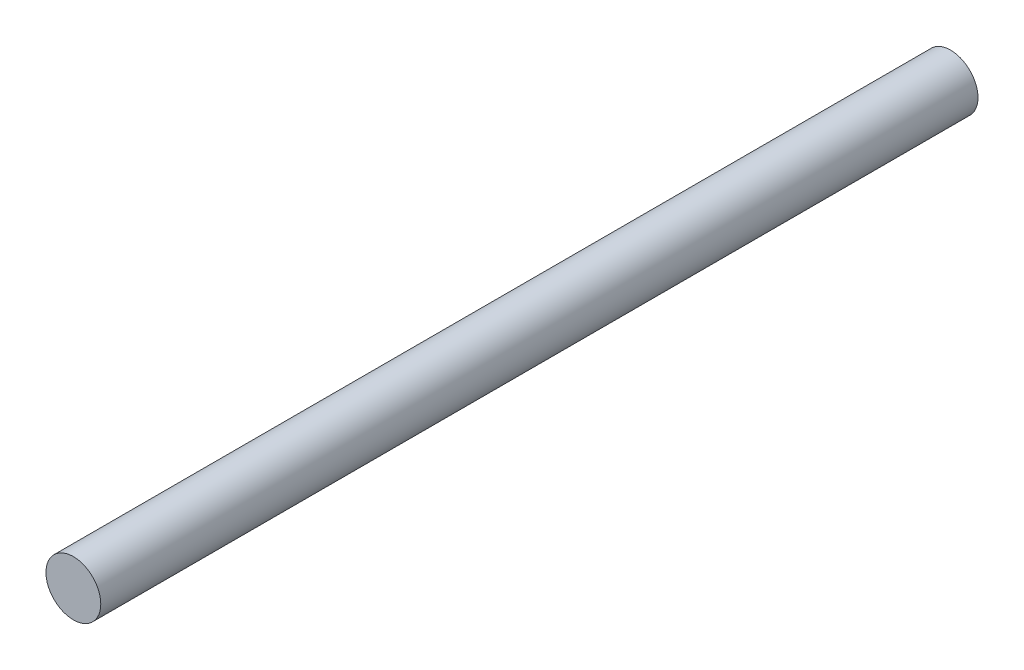
from build123d import *

# Parameters (mm, degrees)
SKETCH1_R           = 19.05
BOSS_EXTRUDE2_DEPTH = 609.6
SKETCH2_W           = 38.1
SKETCH2_H           = 0.0005
CUT_EXTRUDE1_DEPTH  = 50.8
SKETCH5_W           = 38.1
SKETCH5_H           = 0.0005
CUT_EXTRUDE6_DEPTH  = 50.8


with BuildPart() as part:
    # Sketch1 → Boss-Extrude2 (new body)
    with BuildSketch(Plane.XY):
        Circle(SKETCH1_R)
    extrude(amount=BOSS_EXTRUDE2_DEPTH)

    # Sketch2 → Cut-Extrude1 (cut)
    with BuildSketch(Plane(origin=(0, 0, 0), x_dir=(-1, 0, 0), z_dir=(0, 0, -1))):
        with Locations((0, 0.00025)):
            Rectangle(SKETCH2_W, SKETCH2_H)
    extrude(amount=-CUT_EXTRUDE1_DEPTH, mode=Mode.SUBTRACT)

    # Sketch5 → Cut-Extrude6 (cut)
    with BuildSketch(Plane(origin=(0, 0, 0), x_dir=(-1, 0, 0), z_dir=(0, 0, -1))):
        with Locations((0, -0.00025)):
            Rectangle(SKETCH5_W, SKETCH5_H)
    extrude(amount=-CUT_EXTRUDE6_DEPTH, mode=Mode.SUBTRACT)


solid = part.part
